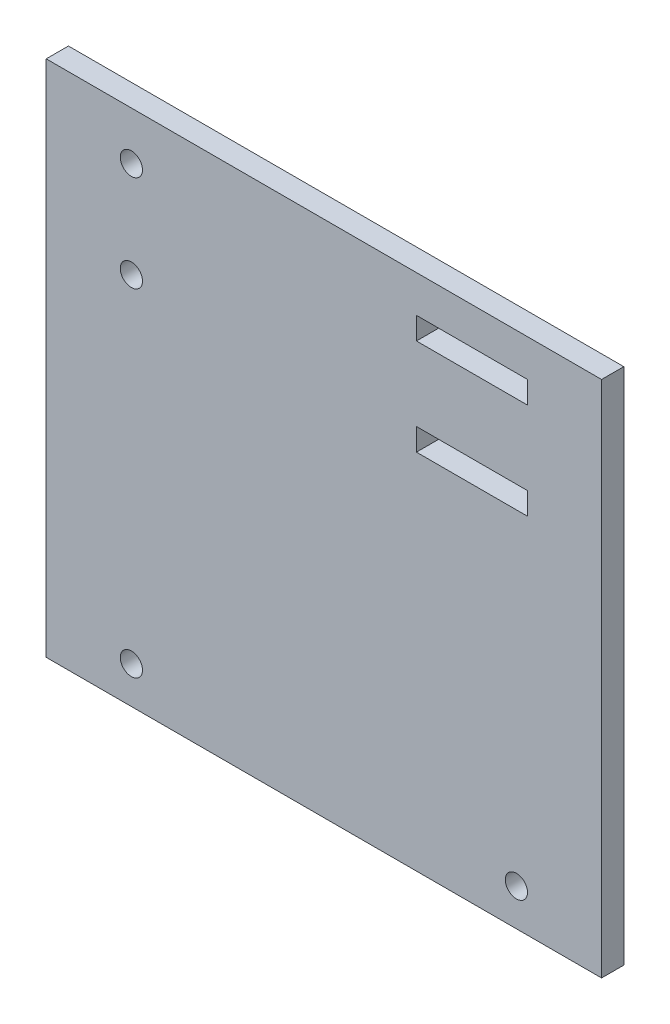
from build123d import *

# Parameters (mm, degrees)
ESQUISSE1_W        = 75
ESQUISSE1_H        = 70
ESQUISSE1_R        = 1.5
ESQUISSE1_W_2      = 15
ESQUISSE1_H_2      = 3
BOSS_EXTRU_1_DEPTH = 3


with BuildPart() as part:
    # Esquisse1 → Boss.-Extru.1 (new body)
    with BuildSketch(Plane.XY):
        with Locations((-12.683673469, -2.836734694)):
            Rectangle(ESQUISSE1_W, ESQUISSE1_H)
        with Locations((-38.683673469, 25.663265306)):
            Circle(ESQUISSE1_R, mode=Mode.SUBTRACT)
        with Locations((-38.683673469, 12.663265306)):
            Circle(ESQUISSE1_R, mode=Mode.SUBTRACT)
        with Locations((-38.683673469, -32.836734694)):
            Circle(ESQUISSE1_R, mode=Mode.SUBTRACT)
        with Locations((13.316326531, -32.836734694)):
            Circle(ESQUISSE1_R, mode=Mode.SUBTRACT)
        with Locations((7.316326531, 12.663265306)):
            Rectangle(ESQUISSE1_W_2, ESQUISSE1_H_2, mode=Mode.SUBTRACT)
        with Locations((7.316326531, 25.663265306)):
            Rectangle(ESQUISSE1_W_2, ESQUISSE1_H_2, mode=Mode.SUBTRACT)
    extrude(amount=BOSS_EXTRU_1_DEPTH)


solid = part.part
